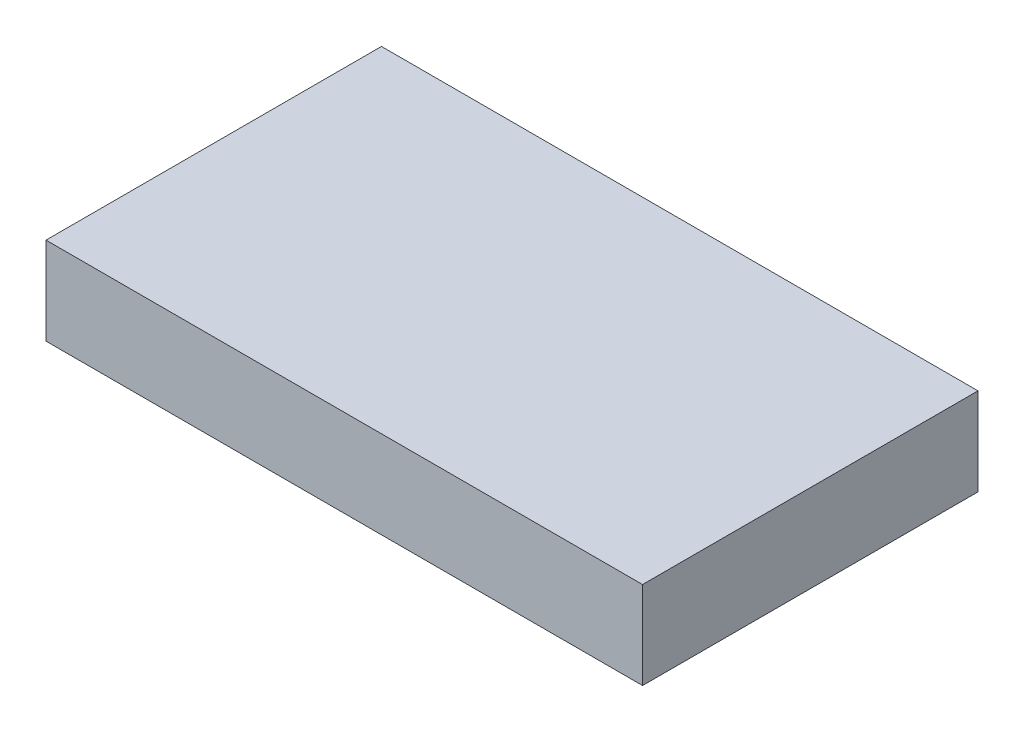
from build123d import *

# Parameters (mm, degrees)
SKETCH1_W           = 103.886
SKETCH1_H           = 58.42
BOSS_EXTRUDE1_DEPTH = 15.24


with BuildPart() as part:
    # Sketch1 → Boss-Extrude1 (new body)
    with BuildSketch(Plane(origin=(0, 0, 0), x_dir=(1, 0, 0), z_dir=(0, 1, 0))):
        with Locations((-19.422165217, 23.636356522)):
            Rectangle(SKETCH1_W, SKETCH1_H)
    extrude(amount=BOSS_EXTRUDE1_DEPTH)


solid = part.part
